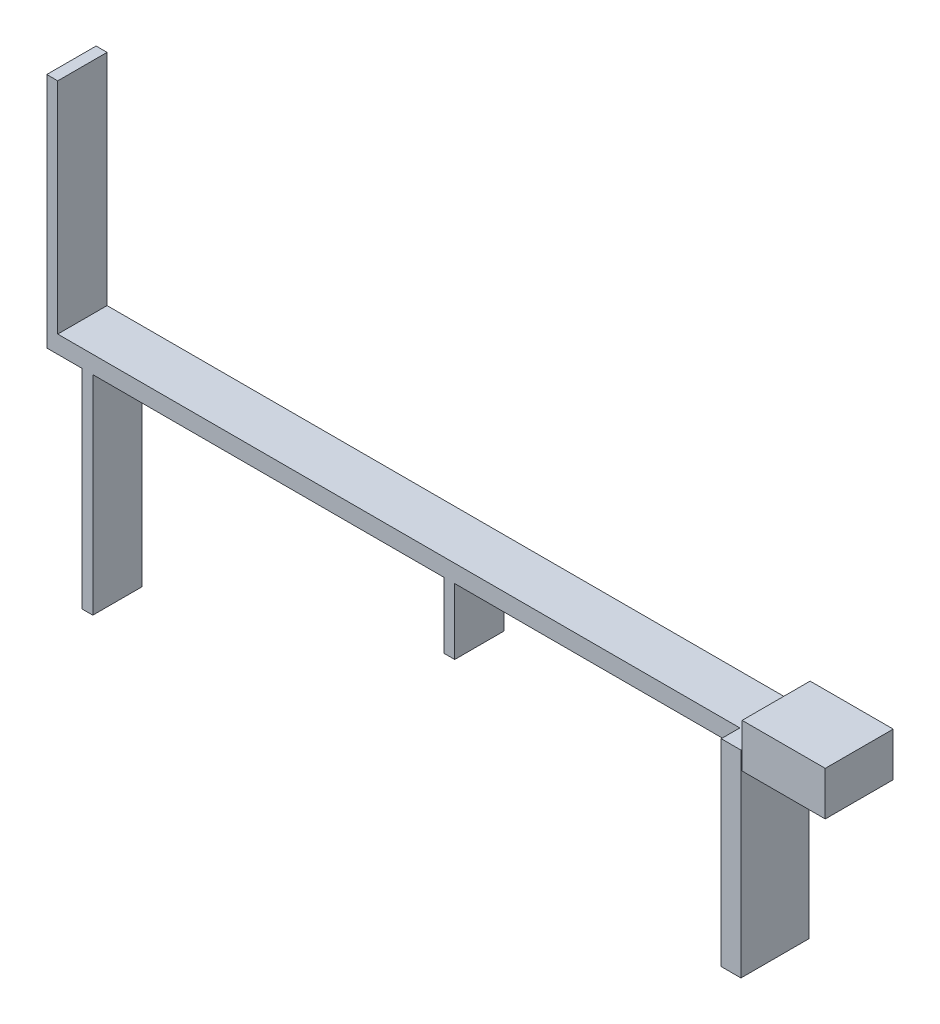
from build123d import *

# Parameters (mm, degrees)
SKETCH1_W      = 7579.868665923
SKETCH1_H      = 4000
EXTRUDE1_DEPTH = 6200
SKETCH2_W      = 1800
SKETCH2_H      = 18000
EXTRUDE2_DEPTH = 6200
SKETCH3_W      = 1000
SKETCH3_H      = 20000
SKETCH3_H_2    = 6000
SKETCH3_H_3    = 19000
EXTRUDE3_DEPTH = 4500


with BuildPart() as part:
    # Sketch1 → Extrude1 (new body)
    with BuildSketch(Plane.XY):
        with Locations((-487.075667039, 34497.694415458)):
            Rectangle(SKETCH1_W, SKETCH1_H)
    extrude(amount=EXTRUDE1_DEPTH)


with BuildPart() as body_2:
    # Sketch2 → Extrude2 (new body)
    with BuildSketch(Plane(origin=(0, 0, 0), x_dir=(-1, 0, 0), z_dir=(0, 0, -1))):
        with Locations((5283.69738863, 25097.694415458)):
            Rectangle(SKETCH2_W, SKETCH2_H)
    extrude(amount=-EXTRUDE2_DEPTH)

    # Sketch3 → Extrude3 (add)
    with BuildSketch(Plane.XY):
        Polygon((-6183.69738863, 32497.694415458), (-6183.69738863, 34097.694415458), (-68383.69738863, 34097.694415458), (-69383.69738863, 34097.694415458), (-69383.69738863, 32497.694415458), (-66183.69738863, 32497.694415458), (-65183.69738863, 32497.694415458), (-33183.69738863, 32497.694415458), (-32183.69738863, 32497.694415458), align=None)
        with Locations((-68883.69738863, 44097.694415458)):
            Rectangle(SKETCH3_W, SKETCH3_H)
        with Locations((-32683.69738863, 29497.694415458)):
            Rectangle(SKETCH3_W, SKETCH3_H_2)
        with Locations((-65683.69738863, 22997.694415458)):
            Rectangle(SKETCH3_W, SKETCH3_H_3)
    extrude(amount=EXTRUDE3_DEPTH)


solid = Compound([part.part, body_2.part])
